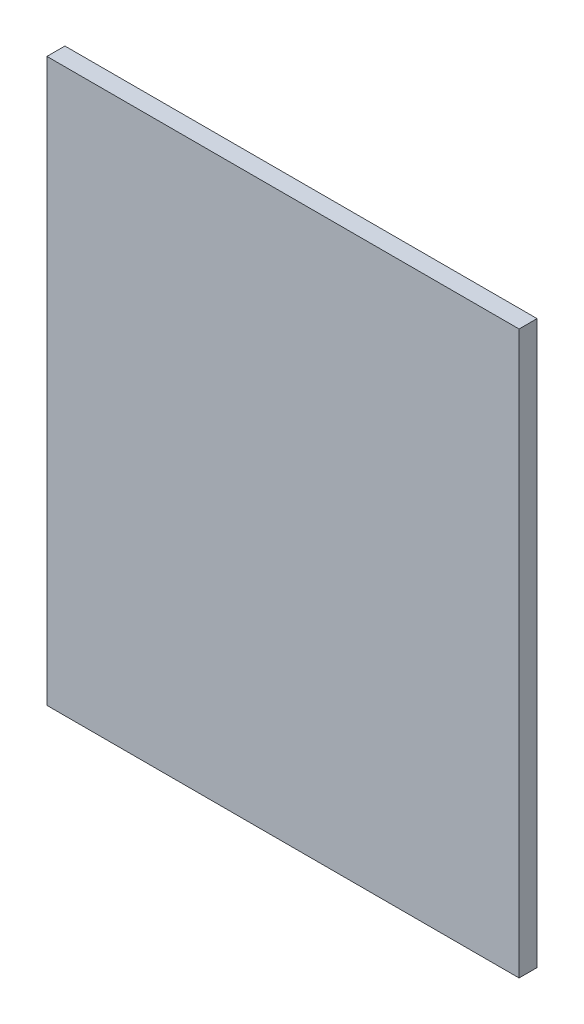
from build123d import *

# Parameters (mm, degrees)
SKETCH1_W           = 42
SKETCH1_H           = 50
BOSS_EXTRUDE1_DEPTH = 1.6


with BuildPart() as part:
    # Sketch1 → Boss-Extrude1 (new body)
    with BuildSketch(Plane.XY):
        Rectangle(SKETCH1_W, SKETCH1_H)
    extrude(amount=BOSS_EXTRUDE1_DEPTH)


solid = part.part
